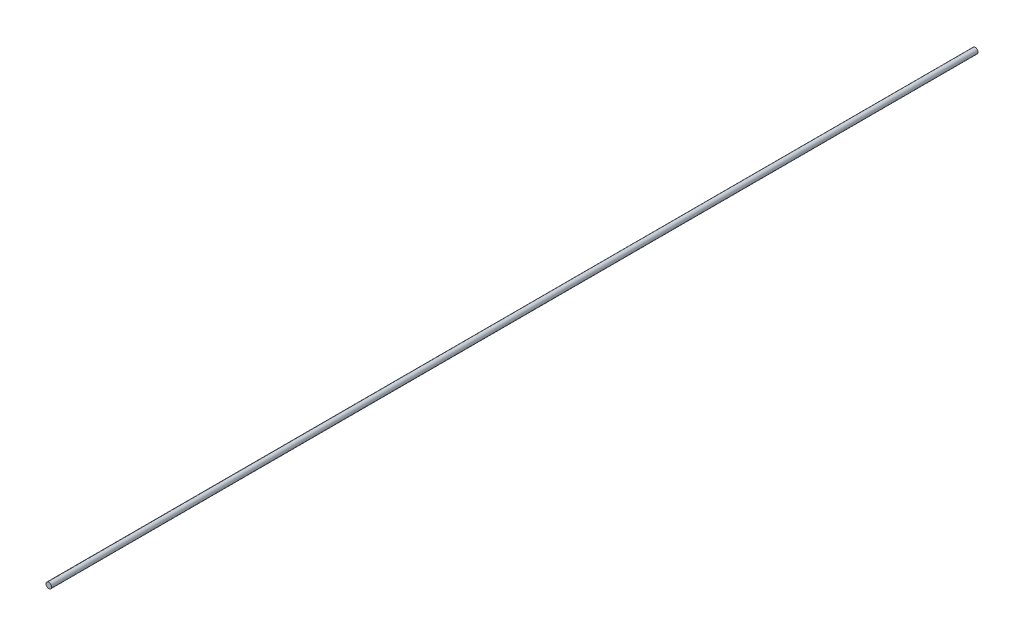
from build123d import *

# Parameters (mm, degrees)
SKETCH1_R           = 6
BOSS_EXTRUDE1_DEPTH = 1000


with BuildPart() as part:
    # Sketch1 → Boss-Extrude1 (new body, symmetric)
    with BuildSketch(Plane.XY):
        Circle(SKETCH1_R)
    extrude(amount=BOSS_EXTRUDE1_DEPTH, both=True)


solid = part.part
